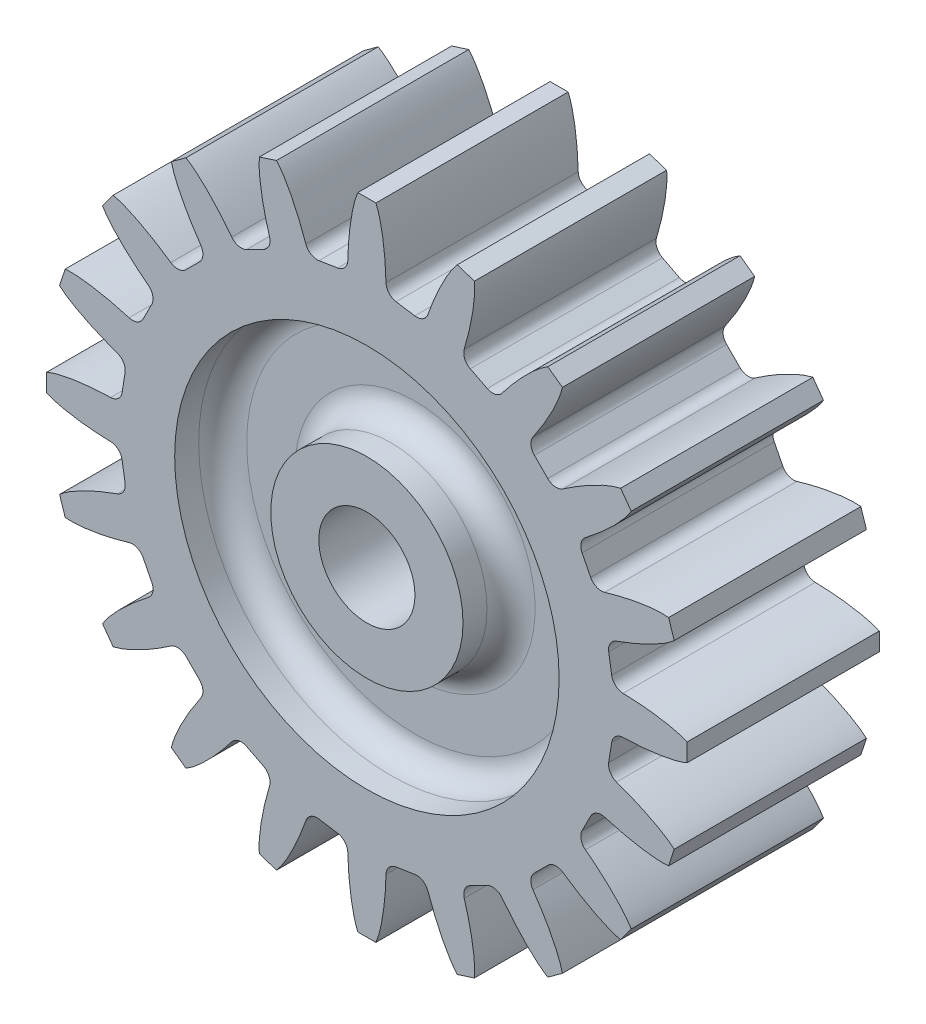
from build123d import *

# Parameters (mm, degrees)
BOSS_EXTRUDE1_DEPTH  = 25.4
SKETCH1_3_R          = 6.35
CUT_EXTRUDE5_DEPTH   = 66.006269842
SKETCH1_4_R          = 25.4
SKETCH1_4_R_2        = 12.7
CUT_EXTRUDE6_DEPTH   = 6.35
FILLET1_R            = 3.175
FILLET1_OF_MIRROR2_R = 3.175


with BuildPart() as part:
    # Sketch1 → Boss-Extrude1 (new body)
    with BuildSketch(Plane.XY):
        with BuildLine():
            Line((1.1938, 42.312262388), (-1.1938, 42.312262388))
            add(Edge.make_bspline(
                [(-1.1938, 42.312262388), (-2.377510064, 39.599192322), (-2.525516491, 33.859618532)],
                knots=[0.489072216, 0.489072216, 0.489072216, 1.460193, 1.460193, 1.460193], degree=2, weights=[1, 0.884413551, 1]))
            ThreePointArc((-2.525516491, 33.859618532), (-2.915588879, 32.862112649), (-3.853440143, 32.344802818))
            Line((-3.853440143, 32.344802818), (-6.330254352, 31.95251396))
            ThreePointArc((-6.330254352, 31.95251396), (-7.382061455, 32.154692854), (-8.061288626, 32.982838336))
            add(Edge.make_bspline(
                [(-8.061288626, 32.982838336), (-9.975676947, 38.395760906), (-11.939836879, 40.610257351)],
                knots=[1.681399651, 1.681399651, 1.681399651, 2.652520438, 2.652520438, 2.652520438], degree=2, weights=[1, 0.88441355, 1]))
            Line((-11.939836879, 40.610257351), (-14.210579417, 39.872448375))
            add(Edge.make_bspline(
                [(-14.210579417, 39.872448375), (-14.49796983, 36.92637888), (-12.865106461, 31.421983317)],
                knots=[3.630664869, 3.630664869, 3.630664869, 4.601785655, 4.601785655, 4.601785655], degree=2, weights=[1, 0.88441355, 1]))
            ThreePointArc((-12.865106461, 31.421983317), (-12.927841082, 30.352759843), (-13.659933119, 29.570956978))
            Line((-13.659933119, 29.570956978), (-15.8942995, 28.432490443))
            ThreePointArc((-15.8942995, 28.432490443), (-16.957104207, 28.299747737), (-17.858998653, 28.877468153))
            add(Edge.make_bspline(
                [(-17.858998653, 28.877468153), (-21.3523752, 33.433884903), (-23.904719335, 34.933037376)],
                knots=[4.822992306, 4.822992306, 4.822992306, 5.794113091, 5.794113091, 5.794113091], degree=2, weights=[1, 0.88441355, 1]))
            Line((-23.904719335, 34.933037376), (-25.836328311, 33.529641308))
            add(Edge.make_bspline(
                [(-25.836328311, 33.529641308), (-25.199267294, 30.638954196), (-21.945370175, 25.908545457)],
                knots=[0.489072216, 0.489072216, 0.489072216, 1.460193001, 1.460193001, 1.460193001], degree=2, weights=[1, 0.88441355, 1]))
            ThreePointArc((-21.945370175, 25.908545457), (-21.67462612, 24.872267441), (-22.129296651, 23.902499851))
            Line((-22.129296651, 23.902499851), (-23.902499851, 22.129296651))
            ThreePointArc((-23.902499851, 22.129296651), (-24.872267441, 21.67462612), (-25.908545457, 21.945370175))
            add(Edge.make_bspline(
                [(-25.908545457, 21.945370175), (-30.638954196, 25.199267294), (-33.529641308, 25.836328311)],
                knots=[1.681399652, 1.681399652, 1.681399652, 2.652520438, 2.652520438, 2.652520438], degree=2, weights=[1, 0.88441355, 1]))
            Line((-33.529641308, 25.836328311), (-34.933037376, 23.904719335))
            add(Edge.make_bspline(
                [(-34.933037376, 23.904719335), (-33.433884903, 21.3523752), (-28.877468153, 17.858998653)],
                knots=[3.630664869, 3.630664869, 3.630664869, 4.601785655, 4.601785655, 4.601785655], degree=2, weights=[1, 0.88441355, 1]))
            ThreePointArc((-28.877468153, 17.858998653), (-28.299747737, 16.957104207), (-28.432490443, 15.8942995))
            Line((-28.432490443, 15.8942995), (-29.570956978, 13.659933119))
            ThreePointArc((-29.570956978, 13.659933119), (-30.352759843, 12.927841082), (-31.421983317, 12.865106461))
            add(Edge.make_bspline(
                [(-31.421983317, 12.865106461), (-36.92637888, 14.49796983), (-39.872448375, 14.210579417)],
                knots=[4.822992306, 4.822992306, 4.822992306, 5.794113091, 5.794113091, 5.794113091], degree=2, weights=[1, 0.88441355, 1]))
            Line((-39.872448375, 14.210579417), (-40.610257351, 11.939836879))
            add(Edge.make_bspline(
                [(-40.610257351, 11.939836879), (-38.395760872, 9.975676917), (-32.982838207, 8.06128858)],
                knots=[0.489072216, 0.489072216, 0.489072216, 1.460193015, 1.460193015, 1.460193015], degree=2, weights=[1, 0.884413547, 1]))
            ThreePointArc((-32.982838207, 8.06128858), (-32.154692388, 7.382060848), (-31.952514032, 6.330253012))
            Line((-31.952514032, 6.330253012), (-32.344805002, 3.853438799))
            ThreePointArc((-32.344805002, 3.853438799), (-32.862115096, 2.915588418), (-33.859620445, 2.525516441))
            add(Edge.make_bspline(
                [(-33.859620445, 2.525516441), (-39.5991929, 2.377509811), (-42.312262388, 1.1938)],
                knots=[4.822992483, 4.822992483, 4.822992483, 5.794113091, 5.794113091, 5.794113091], degree=2, weights=[1, 0.884413592, 1]))
            Line((-42.312262388, 1.1938), (-42.312262388, -1.1938))
            add(Edge.make_bspline(
                [(-42.312262388, -1.1938), (-39.599192318, -2.377510065), (-33.859618519, -2.525516491)],
                knots=[0.489072216, 0.489072216, 0.489072216, 1.460193001, 1.460193001, 1.460193001], degree=2, weights=[1, 0.88441355, 1]))
            ThreePointArc((-33.859618519, -2.525516491), (-32.862112631, -2.915588885), (-32.344802803, -3.853440159))
            Line((-32.344802803, -3.853440159), (-31.95251397, -6.330254372))
            ThreePointArc((-31.95251397, -6.330254372), (-32.154692871, -7.382061466), (-32.982838347, -8.06128863))
            add(Edge.make_bspline(
                [(-32.982838347, -8.06128863), (-38.395760909, -9.97567695), (-40.610257351, -11.939836879)],
                knots=[1.681399652, 1.681399652, 1.681399652, 2.652520438, 2.652520438, 2.652520438], degree=2, weights=[1, 0.88441355, 1]))
            Line((-40.610257351, -11.939836879), (-39.872448375, -14.210579417))
            add(Edge.make_bspline(
                [(-39.872448375, -14.210579417), (-36.92637888, -14.49796983), (-31.421983317, -12.865106461)],
                knots=[3.630664869, 3.630664869, 3.630664869, 4.601785655, 4.601785655, 4.601785655], degree=2, weights=[1, 0.88441355, 1]))
            ThreePointArc((-31.421983317, -12.865106461), (-30.352759843, -12.927841082), (-29.570956978, -13.659933119))
            Line((-29.570956978, -13.659933119), (-28.432490443, -15.8942995))
            ThreePointArc((-28.432490443, -15.8942995), (-28.299747737, -16.957104207), (-28.877468153, -17.858998653))
            add(Edge.make_bspline(
                [(-28.877468153, -17.858998653), (-33.433884903, -21.3523752), (-34.933037376, -23.904719335)],
                knots=[1.681399652, 1.681399652, 1.681399652, 2.652520438, 2.652520438, 2.652520438], degree=2, weights=[1, 0.88441355, 1]))
            Line((-34.933037376, -23.904719335), (-33.529641308, -25.836328311))
            add(Edge.make_bspline(
                [(-33.529641308, -25.836328311), (-30.638954196, -25.199267294), (-25.908545457, -21.945370175)],
                knots=[3.630664869, 3.630664869, 3.630664869, 4.601785655, 4.601785655, 4.601785655], degree=2, weights=[1, 0.88441355, 1]))
            ThreePointArc((-25.908545457, -21.945370175), (-24.872267441, -21.67462612), (-23.902499851, -22.129296651))
            Line((-23.902499851, -22.129296651), (-22.129296651, -23.902499851))
            ThreePointArc((-22.129296651, -23.902499851), (-21.67462612, -24.872267441), (-21.945370175, -25.908545457))
            add(Edge.make_bspline(
                [(-21.945370175, -25.908545457), (-25.199267294, -30.638954196), (-25.836328311, -33.529641308)],
                knots=[4.822992306, 4.822992306, 4.822992306, 5.794113091, 5.794113091, 5.794113091], degree=2, weights=[1, 0.88441355, 1]))
            Line((-25.836328311, -33.529641308), (-23.904719335, -34.933037376))
            add(Edge.make_bspline(
                [(-23.904719335, -34.933037376), (-21.3523752, -33.433884903), (-17.858998653, -28.877468153)],
                knots=[0.489072216, 0.489072216, 0.489072216, 1.460193001, 1.460193001, 1.460193001], degree=2, weights=[1, 0.88441355, 1]))
            ThreePointArc((-17.858998653, -28.877468153), (-16.957104207, -28.299747737), (-15.8942995, -28.432490443))
            Line((-15.8942995, -28.432490443), (-13.659933119, -29.570956978))
            ThreePointArc((-13.659933119, -29.570956978), (-12.927841082, -30.352759843), (-12.865106461, -31.421983317))
            add(Edge.make_bspline(
                [(-12.865106461, -31.421983317), (-14.49796983, -36.92637888), (-14.210579417, -39.872448375)],
                knots=[4.822992306, 4.822992306, 4.822992306, 5.794113091, 5.794113091, 5.794113091], degree=2, weights=[1, 0.88441355, 1]))
            Line((-14.210579417, -39.872448375), (-11.939836879, -40.610257351))
            add(Edge.make_bspline(
                [(-11.939836879, -40.610257351), (-9.97567695, -38.395760909), (-8.06128863, -32.982838347)],
                knots=[0.489072216, 0.489072216, 0.489072216, 1.460193001, 1.460193001, 1.460193001], degree=2, weights=[1, 0.88441355, 1]))
            ThreePointArc((-8.06128863, -32.982838347), (-7.382061466, -32.154692871), (-6.330254372, -31.95251397))
            Line((-6.330254372, -31.95251397), (-3.853440159, -32.344802803))
            ThreePointArc((-3.853440159, -32.344802803), (-2.915588885, -32.862112631), (-2.525516491, -33.859618519))
            add(Edge.make_bspline(
                [(-2.525516491, -33.859618519), (-2.377510065, -39.599192318), (-1.1938, -42.312262388)],
                knots=[4.822992306, 4.822992306, 4.822992306, 5.794113091, 5.794113091, 5.794113091], degree=2, weights=[1, 0.88441355, 1]))
            Line((-1.1938, -42.312262388), (1.1938, -42.312262388))
            add(Edge.make_bspline(
                [(1.1938, -42.312262388), (2.377510065, -39.599192318), (2.525516491, -33.859618519)],
                knots=[0.489072216, 0.489072216, 0.489072216, 1.460193001, 1.460193001, 1.460193001], degree=2, weights=[1, 0.88441355, 1]))
            ThreePointArc((2.525516491, -33.859618519), (2.915588885, -32.862112631), (3.853440159, -32.344802803))
            Line((3.853440159, -32.344802803), (6.330254372, -31.95251397))
            ThreePointArc((6.330254372, -31.95251397), (7.382061466, -32.154692871), (8.06128863, -32.982838347))
            add(Edge.make_bspline(
                [(8.06128863, -32.982838347), (9.97567695, -38.395760909), (11.939836879, -40.610257351)],
                knots=[4.822992306, 4.822992306, 4.822992306, 5.794113091, 5.794113091, 5.794113091], degree=2, weights=[1, 0.88441355, 1]))
            Line((11.939836879, -40.610257351), (14.210579417, -39.872448375))
            add(Edge.make_bspline(
                [(14.210579417, -39.872448375), (14.49796983, -36.92637888), (12.865106461, -31.421983317)],
                knots=[0.489072216, 0.489072216, 0.489072216, 1.460193001, 1.460193001, 1.460193001], degree=2, weights=[1, 0.88441355, 1]))
            ThreePointArc((12.865106461, -31.421983317), (12.927841082, -30.352759843), (13.659933119, -29.570956978))
            Line((13.659933119, -29.570956978), (15.8942995, -28.432490443))
            ThreePointArc((15.8942995, -28.432490443), (16.957104207, -28.299747737), (17.858998653, -28.877468153))
            add(Edge.make_bspline(
                [(17.858998653, -28.877468153), (21.3523752, -33.433884903), (23.904719335, -34.933037376)],
                knots=[1.681399652, 1.681399652, 1.681399652, 2.652520438, 2.652520438, 2.652520438], degree=2, weights=[1, 0.88441355, 1]))
            Line((23.904719335, -34.933037376), (25.836328311, -33.529641308))
            add(Edge.make_bspline(
                [(25.836328311, -33.529641308), (25.199267294, -30.638954196), (21.945370175, -25.908545457)],
                knots=[3.630664869, 3.630664869, 3.630664869, 4.601785655, 4.601785655, 4.601785655], degree=2, weights=[1, 0.88441355, 1]))
            ThreePointArc((21.945370175, -25.908545457), (21.67462612, -24.872267441), (22.129296651, -23.902499851))
            Line((22.129296651, -23.902499851), (23.902499851, -22.129296651))
            ThreePointArc((23.902499851, -22.129296651), (24.872267441, -21.67462612), (25.908545457, -21.945370175))
            add(Edge.make_bspline(
                [(25.908545457, -21.945370175), (30.638954196, -25.199267294), (33.529641308, -25.836328311)],
                knots=[4.822992306, 4.822992306, 4.822992306, 5.794113091, 5.794113091, 5.794113091], degree=2, weights=[1, 0.88441355, 1]))
            Line((33.529641308, -25.836328311), (34.933037376, -23.904719335))
            add(Edge.make_bspline(
                [(34.933037376, -23.904719335), (33.433884903, -21.3523752), (28.877468153, -17.858998653)],
                knots=[0.489072216, 0.489072216, 0.489072216, 1.460193001, 1.460193001, 1.460193001], degree=2, weights=[1, 0.88441355, 1]))
            ThreePointArc((28.877468153, -17.858998653), (28.299747737, -16.957104207), (28.432490443, -15.8942995))
            Line((28.432490443, -15.8942995), (29.570956978, -13.659933119))
            ThreePointArc((29.570956978, -13.659933119), (30.352759843, -12.927841082), (31.421983317, -12.865106461))
            add(Edge.make_bspline(
                [(31.421983317, -12.865106461), (36.92637888, -14.49796983), (39.872448375, -14.210579417)],
                knots=[1.681399652, 1.681399652, 1.681399652, 2.652520438, 2.652520438, 2.652520438], degree=2, weights=[1, 0.88441355, 1]))
            Line((39.872448375, -14.210579417), (40.610257351, -11.939836879))
            add(Edge.make_bspline(
                [(40.610257351, -11.939836879), (38.395760909, -9.97567695), (32.982838347, -8.06128863)],
                knots=[3.630664869, 3.630664869, 3.630664869, 4.601785655, 4.601785655, 4.601785655], degree=2, weights=[1, 0.88441355, 1]))
            ThreePointArc((32.982838347, -8.06128863), (32.154692871, -7.382061466), (31.95251397, -6.330254372))
            Line((31.95251397, -6.330254372), (32.344802803, -3.853440159))
            ThreePointArc((32.344802803, -3.853440159), (32.862112631, -2.915588885), (33.859618519, -2.525516491))
            add(Edge.make_bspline(
                [(33.859618519, -2.525516491), (39.599192318, -2.377510065), (42.312262388, -1.1938)],
                knots=[4.822992306, 4.822992306, 4.822992306, 5.794113091, 5.794113091, 5.794113091], degree=2, weights=[1, 0.88441355, 1]))
            Line((42.312262388, -1.1938), (42.312262388, 1.1938))
            add(Edge.make_bspline(
                [(42.312262388, 1.1938), (39.599192318, 2.377510065), (33.859618519, 2.525516491)],
                knots=[0.489072216, 0.489072216, 0.489072216, 1.460193001, 1.460193001, 1.460193001], degree=2, weights=[1, 0.88441355, 1]))
            ThreePointArc((33.859618519, 2.525516491), (32.862112631, 2.915588885), (32.344802803, 3.853440159))
            Line((32.344802803, 3.853440159), (31.95251397, 6.330254372))
            ThreePointArc((31.95251397, 6.330254372), (32.154692871, 7.382061466), (32.982838347, 8.06128863))
            add(Edge.make_bspline(
                [(32.982838347, 8.06128863), (38.395760909, 9.97567695), (40.610257351, 11.939836879)],
                knots=[1.681399652, 1.681399652, 1.681399652, 2.652520438, 2.652520438, 2.652520438], degree=2, weights=[1, 0.88441355, 1]))
            Line((40.610257351, 11.939836879), (39.872448375, 14.210579417))
            add(Edge.make_bspline(
                [(39.872448375, 14.210579417), (36.92637888, 14.49796983), (31.421983317, 12.865106461)],
                knots=[3.630664869, 3.630664869, 3.630664869, 4.601785655, 4.601785655, 4.601785655], degree=2, weights=[1, 0.88441355, 1]))
            ThreePointArc((31.421983317, 12.865106461), (30.352759843, 12.927841082), (29.570956978, 13.659933119))
            Line((29.570956978, 13.659933119), (28.432490443, 15.8942995))
            ThreePointArc((28.432490443, 15.8942995), (28.299747737, 16.957104207), (28.877468153, 17.858998653))
            add(Edge.make_bspline(
                [(28.877468153, 17.858998653), (33.433884903, 21.3523752), (34.933037376, 23.904719335)],
                knots=[4.822992306, 4.822992306, 4.822992306, 5.794113091, 5.794113091, 5.794113091], degree=2, weights=[1, 0.88441355, 1]))
            Line((34.933037376, 23.904719335), (33.529641308, 25.836328311))
            add(Edge.make_bspline(
                [(33.529641308, 25.836328311), (30.638954196, 25.199267294), (25.908545457, 21.945370175)],
                knots=[0.489072216, 0.489072216, 0.489072216, 1.460193001, 1.460193001, 1.460193001], degree=2, weights=[1, 0.88441355, 1]))
            ThreePointArc((25.908545457, 21.945370175), (24.872267441, 21.67462612), (23.902499851, 22.129296651))
            Line((23.902499851, 22.129296651), (22.129296651, 23.902499851))
            ThreePointArc((22.129296651, 23.902499851), (21.67462612, 24.872267441), (21.945370175, 25.908545457))
            add(Edge.make_bspline(
                [(21.945370175, 25.908545457), (25.199267294, 30.638954196), (25.836328311, 33.529641308)],
                knots=[1.681399652, 1.681399652, 1.681399652, 2.652520438, 2.652520438, 2.652520438], degree=2, weights=[1, 0.88441355, 1]))
            Line((25.836328311, 33.529641308), (23.904719335, 34.933037376))
            add(Edge.make_bspline(
                [(23.904719335, 34.933037376), (21.3523752, 33.433884903), (17.858998653, 28.877468153)],
                knots=[3.630664869, 3.630664869, 3.630664869, 4.601785655, 4.601785655, 4.601785655], degree=2, weights=[1, 0.88441355, 1]))
            ThreePointArc((17.858998653, 28.877468153), (16.957104207, 28.299747737), (15.8942995, 28.432490443))
            Line((15.8942995, 28.432490443), (13.659933119, 29.570956978))
            ThreePointArc((13.659933119, 29.570956978), (12.927841082, 30.352759843), (12.865106461, 31.421983317))
            add(Edge.make_bspline(
                [(12.865106461, 31.421983317), (14.49796983, 36.92637888), (14.210579417, 39.872448375)],
                knots=[1.681399652, 1.681399652, 1.681399652, 2.652520438, 2.652520438, 2.652520438], degree=2, weights=[1, 0.88441355, 1]))
            Line((14.210579417, 39.872448375), (11.939836879, 40.610257351))
            add(Edge.make_bspline(
                [(11.939836879, 40.610257351), (9.975676958, 38.395760918), (8.061288643, 32.982838383)],
                knots=[3.630664869, 3.630664869, 3.630664869, 4.601785652, 4.601785652, 4.601785652], degree=2, weights=[1, 0.884413551, 1]))
            ThreePointArc((8.061288643, 32.982838383), (7.3820615, 32.15469292), (6.330254434, 31.952514))
            Line((6.330254434, 31.952514), (3.853440208, 32.344802756))
            ThreePointArc((3.853440208, 32.344802756), (2.915588901, 32.862112573), (2.525516492, 33.859618481))
            add(Edge.make_bspline(
                [(2.525516492, 33.859618481), (2.37751007, 39.599192307), (1.1938, 42.312262388)],
                knots=[4.822992302, 4.822992302, 4.822992302, 5.794113091, 5.794113091, 5.794113091], degree=2, weights=[1, 0.88441355, 1]))
        make_face()
    extrude(amount=BOSS_EXTRUDE1_DEPTH)

    # Sketch1_3 → Cut-Extrude5 (cut, through all)
    with BuildSketch(Plane.XY):
        Circle(SKETCH1_3_R)
    extrude(amount=CUT_EXTRUDE5_DEPTH, mode=Mode.SUBTRACT)

    # Sketch1_4 → Cut-Extrude6 (cut)
    with BuildSketch(Plane.XY):
        Circle(SKETCH1_4_R)
        Circle(SKETCH1_4_R_2, mode=Mode.SUBTRACT)
    cut_extrude6 = extrude(amount=CUT_EXTRUDE6_DEPTH, mode=Mode.SUBTRACT)

    # Fillet1
    fillet1_edges = [part.edges().sort_by_distance(p)[0] for p in [
        (-12.7, 0, 6.35),
        (-25.4, 0, 6.35),
    ]]
    fillet(fillet1_edges, radius=FILLET1_R)

    # Mirror2: Cut-Extrude6 across plane
    add(cut_extrude6.mirror(Plane(origin=(0, 0, 12.7), x_dir=(1, 0, 0), z_dir=(0, 0, -1))), mode=Mode.SUBTRACT)

    # Fillet1 of Mirror2
    fillet1_of_mirror2_edges = [part.edges().sort_by_distance(p)[0] for p in [
        (-12.7, 0, 19.05),
        (-25.4, 0, 19.05),
    ]]
    fillet(fillet1_of_mirror2_edges, radius=FILLET1_OF_MIRROR2_R)


solid = part.part
